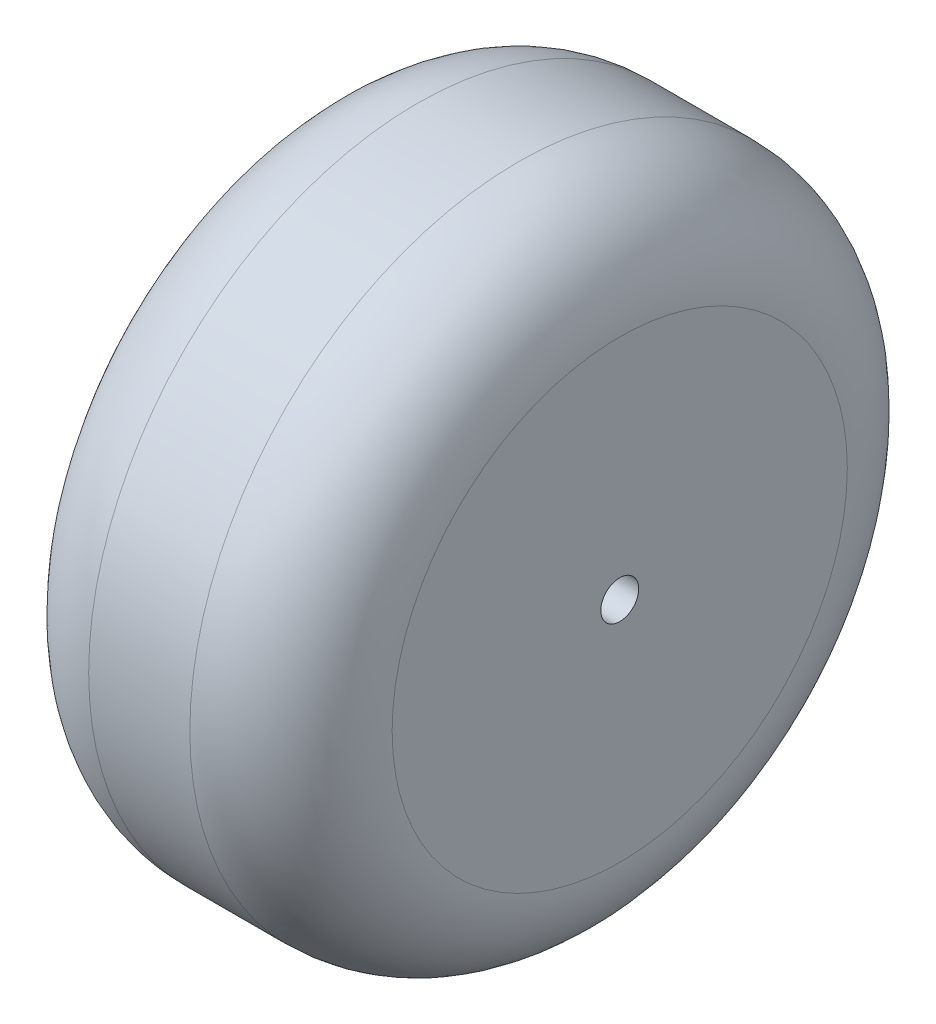
from build123d import *

# Parameters (mm, degrees)
SKETCH1_R           = 41.275
BOSS_EXTRUDE1_DEPTH = 38.1
SKETCH2_R           = 2.38125
CUT_EXTRUDE1_DEPTH  = 39.1
FILLET1_R           = 12.7


with BuildPart() as part:
    # Sketch1 → Boss-Extrude1 (new body)
    with BuildSketch(Plane(origin=(0, 0, 0), x_dir=(0, 0, -1), z_dir=(1, 0, 0))):
        Circle(SKETCH1_R)
    extrude(amount=BOSS_EXTRUDE1_DEPTH)

    # Sketch2 → Cut-Extrude1 (cut, through all)
    with BuildSketch(Plane(origin=(38.1, 0, 0), x_dir=(0, 0, -1), z_dir=(1, 0, 0))):
        Circle(SKETCH2_R)
    extrude(amount=-CUT_EXTRUDE1_DEPTH, mode=Mode.SUBTRACT)

    # Fillet1
    fillet1_edges = [part.edges().sort_by_distance(p)[0] for p in [
        (0, 0, 41.275),
        (38.1, 0, 41.275),
    ]]
    fillet(fillet1_edges, radius=FILLET1_R)


solid = part.part
